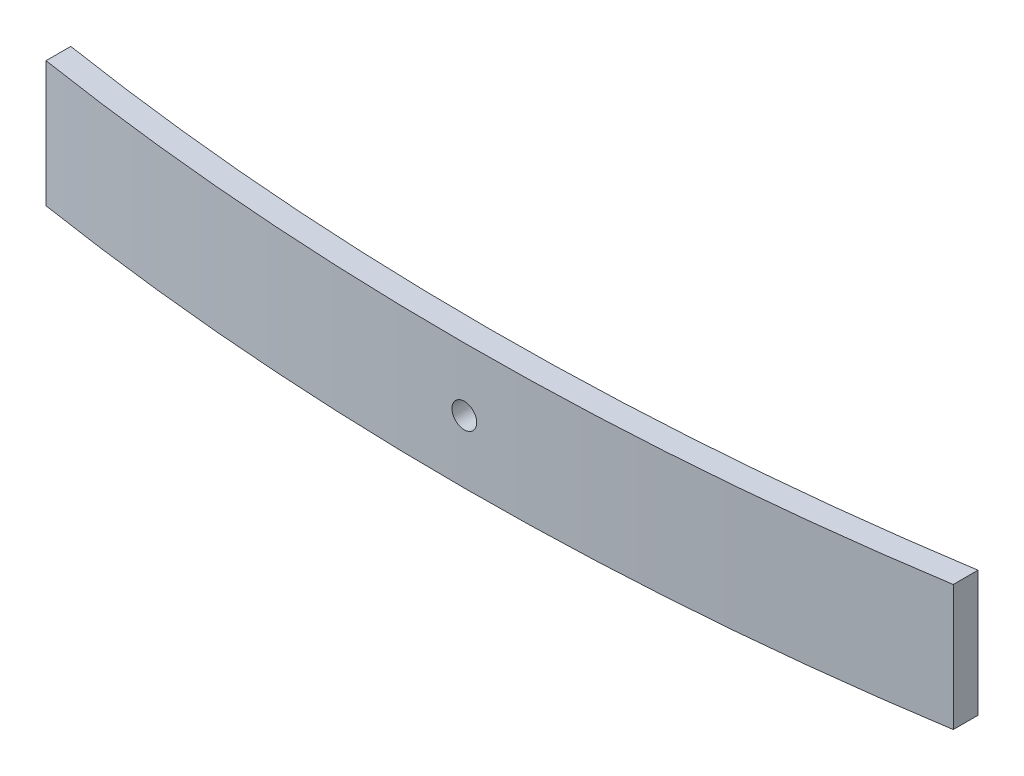
from build123d import *

# Parameters (mm, degrees)
BOSS_EXTRUDE1_DEPTH = 76.2
SKETCH12_R          = 7.5
CUT_EXTRUDE1_DEPTH  = 254


with BuildPart() as part:
    # Sketch1 → Boss-Extrude1 (new body)
    with BuildSketch(Plane(origin=(0, 0, 0), x_dir=(1, 0, 0), z_dir=(0, 1, 0))):
        with BuildLine():
            ThreePointArc((275.021699517, -216.577215773), (0, -238), (-275.021699517, -216.577215773))
            Line((-275.021699517, -216.577215773), (-275.021699517, -231.577215773))
            ThreePointArc((-275.021699517, -231.577215773), (0, -253), (275.021699517, -231.577215773))
            Line((275.021699517, -231.577215773), (275.021699517, -216.577215773))
        make_face()
    extrude(amount=BOSS_EXTRUDE1_DEPTH)

    # Sketch12 → Cut-Extrude1 (cut, through all)
    with BuildSketch(Plane.XY):
        with Locations((0, 38.1)):
            Circle(SKETCH12_R)
    extrude(amount=CUT_EXTRUDE1_DEPTH, mode=Mode.SUBTRACT)


solid = part.part
